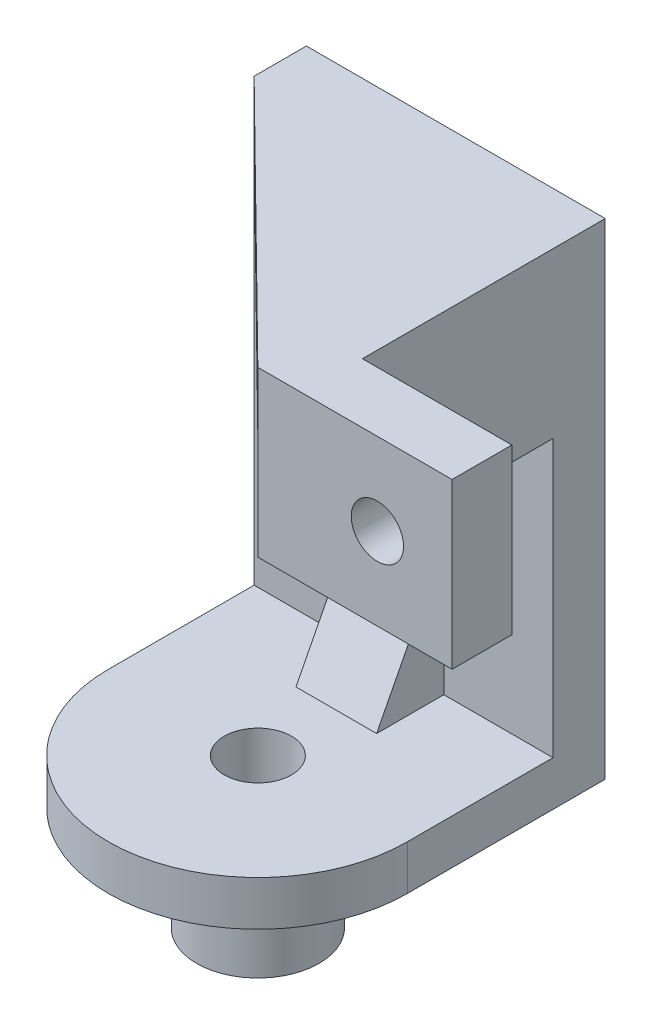
from build123d import *

# Parameters (mm, degrees)
CROQUIS1_W              = 20
CROQUIS1_H              = 13.25
SALIENTE_EXTRUIR1_DEPTH = 3
CROQUIS3_R              = 2.25
CORTAR_EXTRUIR1_DEPTH   = 3
CROQUIS7_W              = 20
CROQUIS7_H              = 3.5
SALIENTE_EXTRUIR4_DEPTH = 25
CROQUIS6_R              = 4.1
CROQUIS6_R_2            = 2.25
SALIENTE_EXTRUIR3_DEPTH = 7
CROQUIS8_R              = 2.25
CORTAR_EXTRUIR3_DEPTH   = 23
NERVIO6_REACH           = 37.527
CROQUIS20_WALL_W        = 82.892721144
CROQUIS20_WALL_H        = 5.4
CROQUIS28_W             = 20
CROQUIS28_H             = 4.5
SALIENTE_EXTRUIR6_DEPTH = 3.5
CROQUIS29_W             = 3
CROQUIS29_H             = 11
SALIENTE_EXTRUIR7_DEPTH = 16.75
CROQUIS31_W             = 4
CROQUIS31_H             = 11
SALIENTE_EXTRUIR8_DEPTH = 10
CROQUIS27_R             = 1.75
CORTAR_EXTRUIR5_DEPTH   = 24
NERVIO7_REACH           = 49.84
CROQUIS32_WALL_W        = 121.545885618
CROQUIS32_WALL_H        = 4


with BuildPart() as part:
    # Croquis1 → Saliente-Extruir1 (new body)
    with BuildSketch(Plane(origin=(0, 0, 0), x_dir=(1, 0, 0), z_dir=(0, 1, 0))):
        with Locations((-8.715974267, 12.820975022)):
            Rectangle(CROQUIS1_W, CROQUIS1_H)
        with BuildLine():
            Line((-18.715974267, 6.195975022), (1.284025733, 6.195975022))
            ThreePointArc((1.284025733, 6.195975022), (-8.715974267, -3.804024978), (-18.715974267, 6.195975022))
        make_face()
    extrude(amount=SALIENTE_EXTRUIR1_DEPTH)

    # Croquis3 → Cortar-Extruir1 (cut)
    with BuildSketch(Plane(origin=(0, 3, 0), x_dir=(1, 0, 0), z_dir=(0, 1, 0))):
        with Locations(Location((-8.715974267, 6.195975022, 0), (0, 0, 270))):
            Circle(CROQUIS3_R)
    extrude(amount=-CORTAR_EXTRUIR1_DEPTH, mode=Mode.SUBTRACT)

    # Croquis7 → Saliente-Extruir4 (add)
    with BuildSketch(Plane(origin=(0, 3, 0), x_dir=(1, 0, 0), z_dir=(0, 1, 0))):
        with Locations((-8.715974267, 17.695975022)):
            Rectangle(CROQUIS7_W, CROQUIS7_H)
    extrude(amount=SALIENTE_EXTRUIR4_DEPTH)

    # Croquis6 → Saliente-Extruir3 (add)
    with BuildSketch(Plane.XZ):
        with Locations(Location((-8.715974267, -6.195975022, 0), (0, 0, 90))):
            Circle(CROQUIS6_R)
        with Locations(Location((-8.715974267, -6.195975022, 0), (0, 0, 90))):
            Circle(CROQUIS6_R_2, mode=Mode.SUBTRACT)
    extrude(amount=SALIENTE_EXTRUIR3_DEPTH)

    # Croquis8 → Cortar-Extruir3 (cut)
    with BuildSketch(Plane(origin=(0, 0, -19.445975022), x_dir=(-1, 0, 0), z_dir=(0, 0, -1))):
        with Locations((8.715974267, 23)):
            Circle(CROQUIS8_R)
    extrude(amount=-CORTAR_EXTRUIR3_DEPTH, mode=Mode.SUBTRACT)

    # Croquis20 wall → Nervio6 (add, up to next)
    with BuildSketch(Plane(origin=(-8.715974267, 7.375, -13.695975022), x_dir=(0, -0.889287802318, 0.457348012621), z_dir=(0, 0.457348012621, 0.889287802318)), mode=Mode.PRIVATE) as nervio6_sk1:
        Rectangle(CROQUIS20_WALL_W, CROQUIS20_WALL_H)
    nervio6_tool1 = extrude(nervio6_sk1.sketch, amount=-NERVIO6_REACH, mode=Mode.PRIVATE) - part.part
    add(nervio6_tool1.solids().sort_by_distance((-8.715974267, 7.375, -13.695975022))[0])

    # Croquis28 → Saliente-Extruir6 (add)
    with BuildSketch(Plane.XY.offset(-15.945975022)):
        with Locations((-8.715974267, 30.25)):
            Rectangle(CROQUIS28_W, CROQUIS28_H)
    extrude(amount=-SALIENTE_EXTRUIR6_DEPTH)

    # Croquis29 → Saliente-Extruir7 (add)
    with BuildSketch(Plane.XY.offset(-15.945975022)):
        with Locations((-0.215974267, 27)):
            Rectangle(CROQUIS29_W, CROQUIS29_H)
    extrude(amount=SALIENTE_EXTRUIR7_DEPTH)

    # Croquis31 → Saliente-Extruir8 (add)
    with BuildSketch(Plane(origin=(1.284025733, 0, 0), x_dir=(0, 0, -1), z_dir=(1, 0, 0))):
        with Locations((1.195975022, 27)):
            Rectangle(CROQUIS31_W, CROQUIS31_H)
    extrude(amount=SALIENTE_EXTRUIR8_DEPTH)

    # Croquis27 → Cortar-Extruir5 (cut)
    with BuildSketch(Plane.XY.offset(-15.945975022)):
        with Locations(Location((6.284025733, 27, 0), (0, 0, 180))):
            Circle(CROQUIS27_R)
    extrude(amount=CORTAR_EXTRUIR5_DEPTH, mode=Mode.SUBTRACT)

    # Croquis32 wall → Nervio7 (add, up to next)
    with BuildSketch(Plane(origin=(-10.215974267, 32.5, -7.570975022), x_dir=(-0.712325066938, 0, -0.701849698306), z_dir=(-0.701849698306, 0, 0.712325066938)), mode=Mode.PRIVATE) as nervio7_sk1:
        with Locations((0, 2)):
            Rectangle(CROQUIS32_WALL_W, CROQUIS32_WALL_H)
    nervio7_tool1 = extrude(nervio7_sk1.sketch, amount=-NERVIO7_REACH, mode=Mode.PRIVATE) - part.part
    add(nervio7_tool1.solids().sort_by_distance((-10.215974267, 32.5, -7.570975022))[0])


solid = part.part
